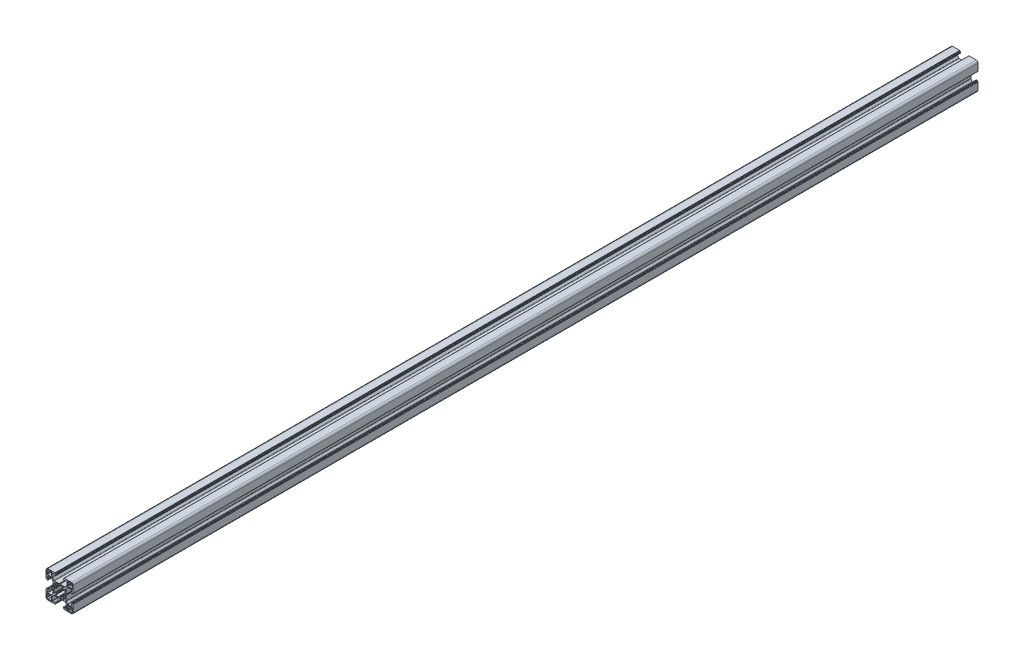
from build123d import *

# Parameters (mm, degrees)
EXTRUDE_1_DEPTH     = 1000
CUT_EXTRUDE_4_DEPTH = 1001
SKETCH_5_W          = 4.9
SKETCH_5_H          = 0.8
CUT_EXTRUDE_1_DEPTH = 1001
CUT_EXTRUDE_3_DEPTH = 1000
CUT_EXTRUDE_5_DEPTH = 1001
CUT_EXTRUDE_6_DEPTH = 1001
FILLET_10_R         = 0.25
FILLET_7_R          = 0.75
FILLET_16_R         = 0.25
FILLET_17_R         = 0.25
FILLET_18_R         = 0.25
FILLET_6_R          = 2
FILLET_19_R         = 1
FILLET_20_R         = 0.4


with BuildPart() as part:
    # Sketch 3 → Extrude 1 (new body)
    with BuildSketch(Plane.XY):
        with BuildLine():
            Line((-15, 15), (-4.1, 15))
            Line((-4.1, 15), (-4.1, 12.8))
            Line((-4.1, 12.8), (-8.1, 12.8))
            Line((-8.1, 12.8), (-8.1, 9.089949494))
            Line((-8.1, 9.089949494), (-6.010050506, 7))
            Line((-6.010050506, 7), (0, 7))
            Line((0, 7), (0, 5))
            ThreePointArc((0, 5), (-1.913417162, 4.619397663), (-3.535533906, 3.535533906))
            Line((-3.535533906, 3.535533906), (-15, 15))
        make_face()
    extrude(amount=-EXTRUDE_1_DEPTH)

    # Sketch 12 → Cut-Extrude 4 (cut, through all)
    with BuildSketch(Plane.XY):
        with BuildLine():
            Line((-14.1, 9), (-14.1, 14.1))
            Line((-14.1, 14.1), (-12.7, 14.1))
            ThreePointArc((-12.7, 14.1), (-11.55, 13.825), (-10.4, 14.1))
            Line((-10.4, 14.1), (-9, 14.1))
            Line((-9, 14.1), (-9, 12.7))
            ThreePointArc((-9, 12.7), (-9.175, 11.55), (-9, 10.4))
            Line((-9, 10.4), (-9, 9))
            Line((-9, 9), (-14.1, 9))
        make_face()
    extrude(amount=-CUT_EXTRUDE_4_DEPTH, mode=Mode.SUBTRACT)

    # Sketch 5 → Cut-Extrude 1 (cut, through all)
    with BuildSketch(Plane.XY):
        with Locations((-2.45, 14.6)):
            Rectangle(SKETCH_5_W, SKETCH_5_H)
    extrude(amount=-CUT_EXTRUDE_1_DEPTH, mode=Mode.SUBTRACT)

    # Sketch 11 → Cut-Extrude 3 (cut)
    with BuildSketch(Plane.XY):
        Polygon((0, 7), (-0.45, 7), (0, 6.7), align=None)
    extrude(amount=-CUT_EXTRUDE_3_DEPTH, mode=Mode.SUBTRACT)

    # Sketch 13 → Cut-Extrude 5 (cut, through all)
    with BuildSketch(Plane.XY):
        Polygon((-8.1, 12.8), (-8.1, 13.4), (-6.1, 13.4), (-5.7, 12.8), align=None)
    extrude(amount=-CUT_EXTRUDE_5_DEPTH, mode=Mode.SUBTRACT)

    # Sketch 14 → Cut-Extrude 6 (cut, through all)
    with BuildSketch(Plane.XY):
        with BuildLine():
            Line((-5.010050506, 6), (-3.202987828, 3.839383931))
            ThreePointArc((-3.202987828, 3.839383931), (-1.913417162, 4.619397663), (-0.45, 4.979708827))
            Line((-0.45, 4.979708827), (-0.6, 6))
            Line((-0.6, 6), (-5.010050506, 6))
        make_face()
    extrude(amount=-CUT_EXTRUDE_6_DEPTH, mode=Mode.SUBTRACT)

    # Fillet 10
    fillet_10_edges = [part.edges().sort_by_distance(p)[0] for p in [
        (-4.1, 12.8, -500),
    ]]
    fillet(fillet_10_edges, radius=FILLET_10_R)

    # Fillet 7
    fillet_7_edges = [part.edges().sort_by_distance(p)[0] for p in [
        (-8.1, 9.089949494, -500),
        (-6.010050506, 7, -500),
    ]]
    fillet(fillet_7_edges, radius=FILLET_7_R)

    # Fillet 16
    fillet_16_edges = [part.edges().sort_by_distance(p)[0] for p in [
        (-4.1, 14.2, -500),
        (-4.9, 15, -500),
        (-0.45, 7, -500),
    ]]
    fillet(fillet_16_edges, radius=FILLET_16_R)

    # Fillet 17
    fillet_17_edges = [part.edges().sort_by_distance(p)[0] for p in [
        (-9, 14.1, -500),
        (-5.7, 12.8, -500),
        (-8.1, 13.4, -500),
        (-6.1, 13.4, -500),
    ]]
    fillet(fillet_17_edges, radius=FILLET_17_R)

    # Fillet 18
    fillet_18_edges = [part.edges().sort_by_distance(p)[0] for p in [
        (-5.010050506, 6, -500),
        (-0.6, 6, -500),
        (-0.45, 4.979708827, -500),
        (-3.202987828, 3.839383931, -500),
    ]]
    fillet(fillet_18_edges, radius=FILLET_18_R)

    # Mirror 21: part across plane


with BuildPart() as part_1:
    add(part.part)
    add(part.part.mirror(Plane(origin=(-3.535533906, 3.535533906, -1000), x_dir=(0, 0, 1), z_dir=(-0.707106781, -0.707106781, 0))))

    # Fillet 6
    fillet_6_edges = [part_1.edges().sort_by_distance(p)[0] for p in [
        (-15, 15, -500),
    ]]
    fillet(fillet_6_edges, radius=FILLET_6_R)

    # Fillet 19
    fillet_19_edges = [part_1.edges().sort_by_distance(p)[0] for p in [
        (-14.1, 14.1, -500),
    ]]
    fillet(fillet_19_edges, radius=FILLET_19_R)

    # Fillet 20
    fillet_20_edges = [part_1.edges().sort_by_distance(p)[0] for p in [
        (-9, 9, -500),
    ]]
    fillet(fillet_20_edges, radius=FILLET_20_R)

    # Mirror 22: part across plane


with BuildPart() as part_2:
    add(part_1.part)
    add(part_1.part.mirror(Plane(origin=(0, 7, -1000), x_dir=(0, 0, 1), z_dir=(1, 0, 0))))

    # Mirror 23: part across plane


with BuildPart() as part_3:
    add(part_2.part)
    add(part_2.part.mirror(Plane(origin=(7, 0, -1000), x_dir=(0, 0, 1), z_dir=(0, -1, 0))))


solid = part_3.part
